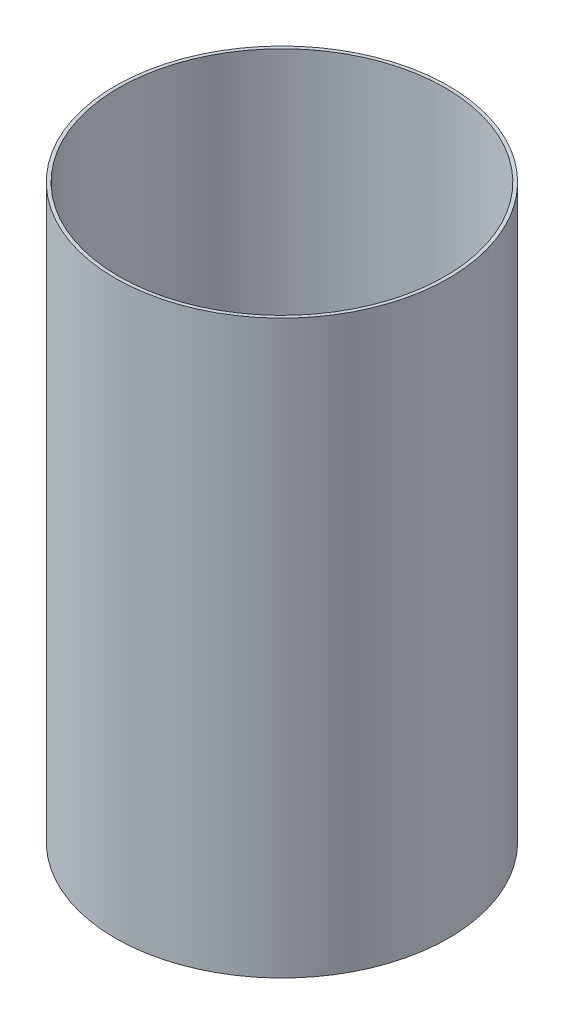
from build123d import *

# Parameters (mm, degrees)
SKETCH2_W = 0.7874
SKETCH2_H = 133.35


with BuildPart() as part:
    # Sketch2 → Revolve1 (revolve)
    with BuildSketch(Plane.XY):
        with Locations((-38.4937, -66.675)):
            Rectangle(SKETCH2_W, SKETCH2_H)
    revolve(axis=Axis((0, 55, 0), (0, -1, 0)))


solid = part.part
